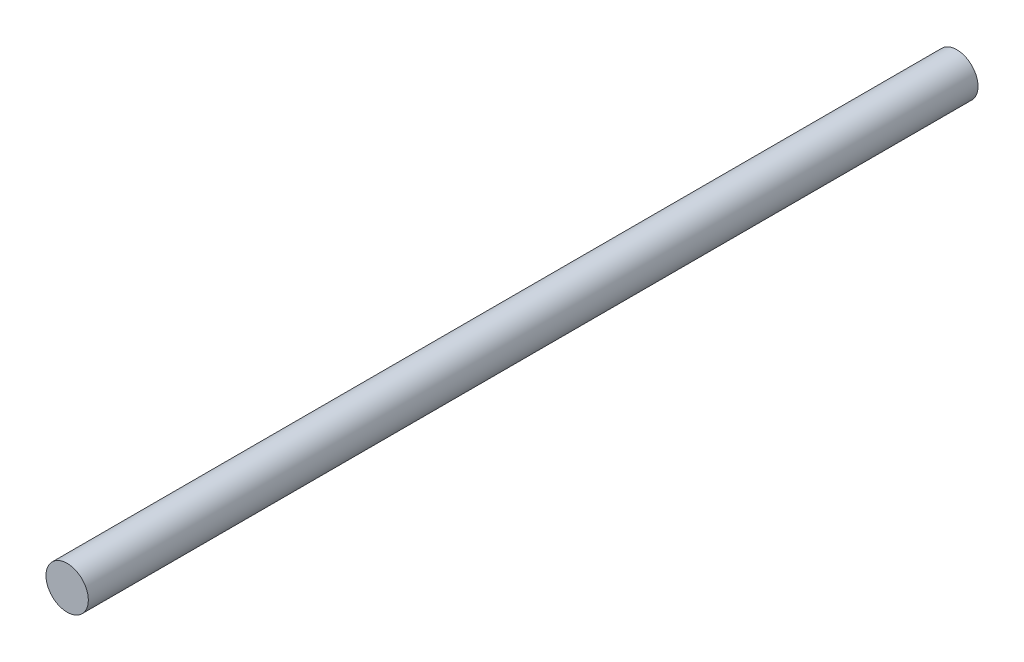
from build123d import *

# Parameters (mm, degrees)
SKETCH1_R           = 1
BOSS_EXTRUDE1_DEPTH = 42


with BuildPart() as part:
    # Sketch1 → Boss-Extrude1 (new body)
    with BuildSketch(Plane.XY):
        with Locations((-0.573038225, -0.819528641)):
            Circle(SKETCH1_R)
    extrude(amount=BOSS_EXTRUDE1_DEPTH)


solid = part.part
